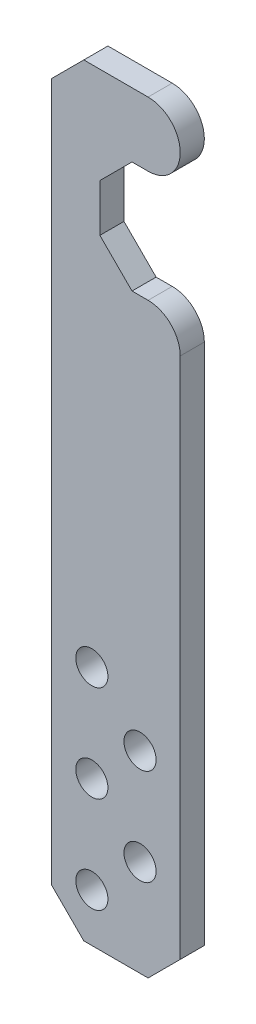
from build123d import *

# Parameters (mm, degrees)
BOSS_EXTRUDE1_DEPTH = 1.5
SKETCH2_R           = 1
CUT_EXTRUDE1_DEPTH  = 5
CHAMFER1_SIZE       = 2


with BuildPart() as part:
    # Sketch1 → Boss-Extrude1 (new body)
    with BuildSketch(Plane.XY):
        with BuildLine():
            Line((-4, -100), (4, -100))
            Line((4, -100), (4, -65.477225575))
            ThreePointArc((4, -65.477225575), (3.414213562, -64.063012013), (2, -63.477225575))
            Line((2, -63.477225575), (-1, -63.477225575))
            Line((-1, -63.477225575), (-1, -56.522774425))
            Line((-1, -56.522774425), (2, -56.522774425))
            ThreePointArc((2, -56.522774425), (4, -54.522774425), (2, -52.522774425))
            Line((2, -52.522774425), (-4, -52.522774425))
            Line((-4, -52.522774425), (-4, -100))
        make_face()
    extrude(amount=BOSS_EXTRUDE1_DEPTH)

    # Sketch2 → Cut-Extrude1 (cut)
    with BuildSketch(Plane.XY.offset(1.5)):
        with Locations((-1.5, -97)):
            Circle(SKETCH2_R)
        with Locations((1.5, -94)):
            Circle(SKETCH2_R)
        with Locations((-1.5, -91)):
            Circle(SKETCH2_R)
        with Locations((-1.5, -85)):
            Circle(SKETCH2_R)
        with Locations((1.5, -88)):
            Circle(SKETCH2_R)
    extrude(amount=-CUT_EXTRUDE1_DEPTH, mode=Mode.SUBTRACT)

    # Chamfer1
    chamfer1_edges = [part.edges().sort_by_distance(p)[0] for p in [
        (-4, -52.522774425, 0.75),
        (-1, -56.522774425, 0.75),
        (-1, -63.477225575, 0.75),
        (4, -100, 0.75),
        (-4, -100, 0.75),
    ]]
    chamfer(chamfer1_edges, length=CHAMFER1_SIZE)


solid = part.part
